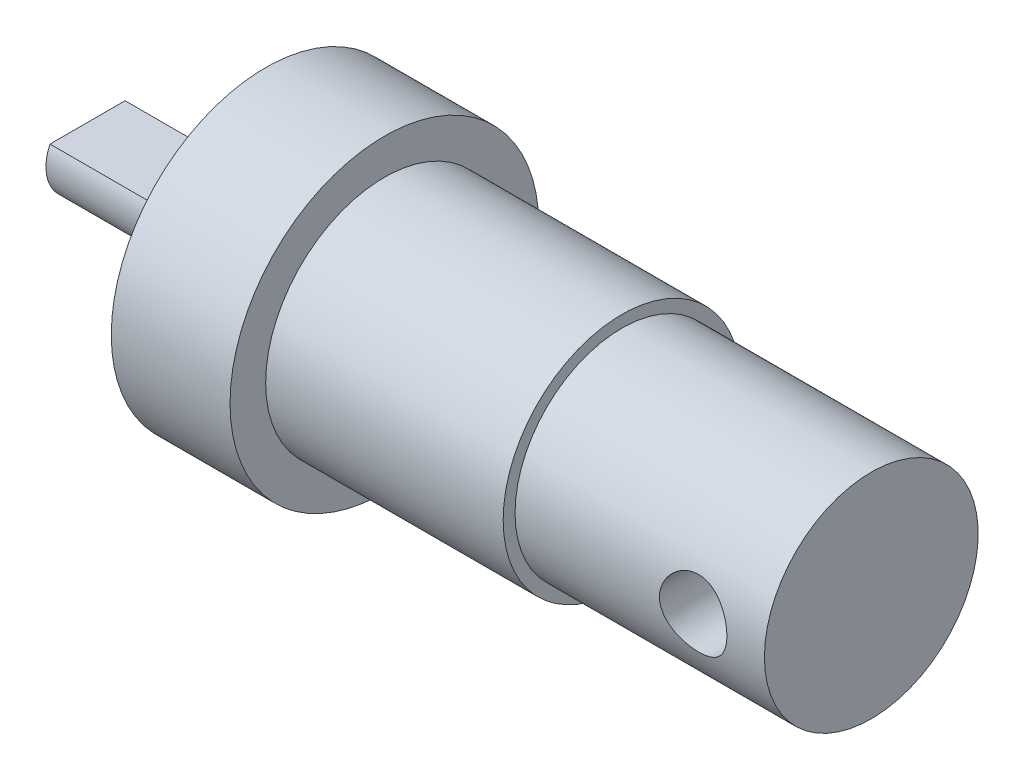
from build123d import *

# Parameters (mm, degrees)
EXTRUDE_2_DEPTH = 7.5


with BuildPart() as part:
    # 草图1 → 旋转1 (revolve)
    with BuildSketch(Plane.XY):
        Polygon((-5, 0), (0, 0), (20.5, 0), (20.5, 4.5), (10, 4.5), (10, 5), (0, 5), (0, 6.5), (-5, 6.5), (-5, 5), align=None)
    revolve(axis=Axis((-5, 0, 0), (1, 0, 0)))

    # 草图3 → 切除-旋转1 (revolve, cut)
    with BuildSketch(Plane(origin=(17.5, 0, 0), x_dir=(0, 0, -1), z_dir=(1, 0, 0))):
        Polygon((-6.680542038, 0), (-6.680542038, 1.407519777), (7.599960071, 1.407519777), (7.599960071, -0.067480223), align=None)
    revolve(axis=Axis((17.5, 0, 6.680542038), (0, -0.004725287, -0.999988836)), mode=Mode.SUBTRACT)

    # 草图4 → 凸台-拉伸2 (add)
    with BuildSketch(Plane.ZY.offset(5)):
        with BuildLine():
            Line((0.04652715, 0.75), (0, 0.75))
            Line((0, 0.75), (-1.58113883, 0.75))
            ThreePointArc((-1.58113883, 0.75), (0, -1.75), (1.58113883, 0.75))
            Line((1.58113883, 0.75), (0.04652715, 0.75))
        make_face()
    extrude(amount=EXTRUDE_2_DEPTH)


solid = part.part
